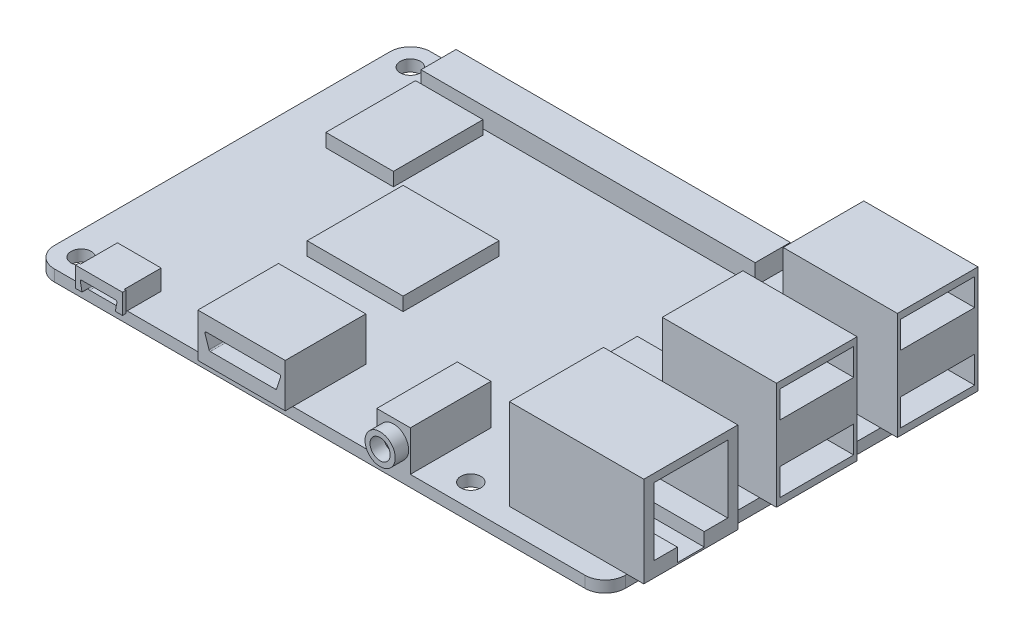
from build123d import *

# Parameters (mm, degrees)
SKETCH1_R            = 3
SKETCH1_R_2          = 1.5
BOSS_EXTRUDE1_DEPTH  = 1.7
SKETCH4_W            = 49.75
SKETCH4_H            = 5.233449475
BOSS_EXTRUDE4_DEPTH  = 3
SKETCH7_W            = 6.5
SKETCH7_H            = 5.5
SKETCH7_W_2          = 7
SKETCH7_H_2          = 0.5
BOSS_EXTRUDE7_DEPTH  = 3
SKETCH8_W            = 13
SKETCH8_H            = 12
BOSS_EXTRUDE8_DEPTH  = 6.5
SKETCH9_W            = 5
SKETCH9_H            = 12
BOSS_EXTRUDE9_DEPTH  = 6
SKETCH10_W           = 20
SKETCH10_H           = 14
BOSS_EXTRUDE10_DEPTH = 13.5
SKETCH11_W           = 17
SKETCH11_H           = 12
BOSS_EXTRUDE11_DEPTH = 16
SKETCH12_W           = 10.053569384
SKETCH12_H           = 13.342225903
SKETCH12_W_2         = 14.279787724
SKETCH12_H_2         = 14.279787724
SKETCH12_W_3         = 9
SKETCH12_H_3         = 9
BOSS_EXTRUDE12_DEPTH = 2
SKETCH13_R           = 2.25
SKETCH13_R_2         = 1.5
BOSS_EXTRUDE13_DEPTH = 2
CUT_EXTRUDE1_DEPTH   = 9
CUT_EXTRUDE2_DEPTH   = 5
SKETCH16_W           = 11
SKETCH16_H           = 4
CUT_EXTRUDE3_DEPTH   = 10
SKETCH17_W           = 11
SKETCH17_H           = 4
CUT_EXTRUDE4_DEPTH   = 10
CUT_EXTRUDE5_DEPTH   = 12


with BuildPart() as part:
    # Sketch1 → Boss-Extrude1 (new body)
    with BuildSketch(Plane(origin=(0, 0, 0), x_dir=(1, 0, 0), z_dir=(0, 1, 0))):
        with BuildLine():
            ThreePointArc((39.5, 24.5), (41.621320344, 23.621320344), (42.5, 21.5))
            Line((42.5, 21.5), (42.5, -28.5))
            ThreePointArc((42.5, -28.5), (41.621320344, -30.621320344), (39.5, -31.5))
            Line((39.5, -31.5), (-39.5, -31.5))
            ThreePointArc((-39.5, -31.5), (-41.621320344, -30.621320344), (-42.5, -28.5))
            Line((-42.5, -28.5), (-42.5, 21.5))
            ThreePointArc((-42.5, 21.5), (-41.621320344, 23.621320344), (-39.5, 24.5))
            Line((-39.5, 24.5), (39.5, 24.5))
        make_face()
        with Locations((19, -28)):
            Circle(SKETCH1_R, mode=Mode.SUBTRACT)
        with Locations((19, 21)):
            Circle(SKETCH1_R, mode=Mode.SUBTRACT)
        with Locations((-39, -28)):
            Circle(SKETCH1_R, mode=Mode.SUBTRACT)
        with Locations((-39, 21)):
            Circle(SKETCH1_R, mode=Mode.SUBTRACT)
        with Locations((19, 21)):
            Circle(SKETCH1_R)
        with Locations((19, 21)):
            Circle(SKETCH1_R_2, mode=Mode.SUBTRACT)
        with Locations((-39, 21)):
            Circle(SKETCH1_R)
        with Locations((-39, 21)):
            Circle(SKETCH1_R_2, mode=Mode.SUBTRACT)
        with Locations((-39, -28)):
            Circle(SKETCH1_R)
        with Locations((-39, -28)):
            Circle(SKETCH1_R_2, mode=Mode.SUBTRACT)
        with Locations((19, -28)):
            Circle(SKETCH1_R)
        with Locations((19, -28)):
            Circle(SKETCH1_R_2, mode=Mode.SUBTRACT)
    extrude(amount=BOSS_EXTRUDE1_DEPTH)

    # Sketch4 → Boss-Extrude4 (add)
    with BuildSketch(Plane(origin=(0, 1.7, 0), x_dir=(1, 0, 0), z_dir=(0, 1, 0))):
        with Locations((-10, 21.068102783)):
            Rectangle(SKETCH4_W, SKETCH4_H)
    extrude(amount=BOSS_EXTRUDE4_DEPTH)

    # Sketch7 → Boss-Extrude7 (add)
    with BuildSketch(Plane(origin=(0, 1.7, 0), x_dir=(1, 0, 0), z_dir=(0, 1, 0))):
        with Locations((-31.9, -29.194183223)):
            Rectangle(SKETCH7_W, SKETCH7_H)
        with Locations((-31.9, -32.194183223)):
            Rectangle(SKETCH7_W_2, SKETCH7_H_2)
    extrude(amount=BOSS_EXTRUDE7_DEPTH)

    # Sketch8 → Boss-Extrude8 (add)
    with BuildSketch(Plane(origin=(0, 1.7, 0), x_dir=(1, 0, 0), z_dir=(0, 1, 0))):
        with Locations((-10.5, -26.626453528)):
            Rectangle(SKETCH8_W, SKETCH8_H)
    extrude(amount=BOSS_EXTRUDE8_DEPTH)

    # Sketch9 → Boss-Extrude9 (add)
    with BuildSketch(Plane(origin=(0, 1.7, 0), x_dir=(1, 0, 0), z_dir=(0, 1, 0))):
        with Locations((11, -25.5)):
            Rectangle(SKETCH9_W, SKETCH9_H)
    extrude(amount=BOSS_EXTRUDE9_DEPTH)

    # Sketch10 → Boss-Extrude10 (add)
    with BuildSketch(Plane(origin=(0, 1.7, 0), x_dir=(1, 0, 0), z_dir=(0, 1, 0))):
        with Locations((35, -21.25)):
            Rectangle(SKETCH10_W, SKETCH10_H)
    extrude(amount=BOSS_EXTRUDE10_DEPTH)

    # Sketch11 → Boss-Extrude11 (add)
    with BuildSketch(Plane(origin=(0, 1.7, 0), x_dir=(1, 0, 0), z_dir=(0, 1, 0))):
        with Locations((36.5, -2.5)):
            Rectangle(SKETCH11_W, SKETCH11_H)
        with Locations((36.5, 15.5)):
            Rectangle(SKETCH11_W, SKETCH11_H)
    extrude(amount=BOSS_EXTRUDE11_DEPTH)

    # Sketch12 → Boss-Extrude12 (add)
    with BuildSketch(Plane(origin=(0, 1.7, 0), x_dir=(1, 0, 0), z_dir=(0, 1, 0))):
        with Locations((-29.848215308, 10.97382243)):
            Rectangle(SKETCH12_W, SKETCH12_H)
        with Locations((-15.157331854, -3.918986484)):
            Rectangle(SKETCH12_W_2, SKETCH12_H_2)
        with Locations((19.1, -3.31)):
            Rectangle(SKETCH12_W_3, SKETCH12_H_3)
    extrude(amount=BOSS_EXTRUDE12_DEPTH)

    # Sketch13 → Boss-Extrude13 (add)
    with BuildSketch(Plane.XY.offset(31.5)):
        with Locations((11, 4.7)):
            Circle(SKETCH13_R)
        with Locations((11, 4.7)):
            Circle(SKETCH13_R_2, mode=Mode.SUBTRACT)
    extrude(amount=BOSS_EXTRUDE13_DEPTH)

    # Sketch14 → Cut-Extrude1 (cut)
    with BuildSketch(Plane.XY.offset(32.626453528)):
        with BuildLine():
            Line((-15.750323675, 5.983842352), (-4.86762122, 5.983842352))
            ThreePointArc((-4.86762122, 5.983842352), (-4.705559797, 5.901043441), (-4.677683467, 5.721203306))
            Line((-4.677683467, 5.721203306), (-5.276717124, 3.904778668))
            ThreePointArc((-5.276717124, 3.904778668), (-5.349453787, 3.805356292), (-5.466654877, 3.767417714))
            Line((-5.466654877, 3.767417714), (-15.151290018, 3.767417714))
            ThreePointArc((-15.151290018, 3.767417714), (-15.268491107, 3.805356292), (-15.341227771, 3.904778668))
            Line((-15.341227771, 3.904778668), (-15.940261428, 5.721203306))
            ThreePointArc((-15.940261428, 5.721203306), (-15.912385097, 5.901043441), (-15.750323675, 5.983842352))
        make_face()
    extrude(amount=-CUT_EXTRUDE1_DEPTH, mode=Mode.SUBTRACT)

    # Sketch15 → Cut-Extrude2 (cut)
    with BuildSketch(Plane.XY.offset(32.444183223)):
        with BuildLine():
            Line((-34.475250903, 3.20419671), (-29.43081526, 3.20419671))
            ThreePointArc((-29.43081526, 3.20419671), (-29.27664987, 3.131605628), (-29.234394805, 2.966527034))
            Line((-29.234394805, 2.966527034), (-29.471007813, 1.732759202))
            ThreePointArc((-29.471007813, 1.732759202), (-29.540019351, 1.616263488), (-29.667428269, 1.570428878))
            Line((-29.667428269, 1.570428878), (-34.24114908, 1.570428878))
            ThreePointArc((-34.24114908, 1.570428878), (-34.36870932, 1.616388672), (-34.437643137, 1.733145027))
            Line((-34.437643137, 1.733145027), (-34.67174496, 2.966912859))
            ThreePointArc((-34.67174496, 2.966912859), (-34.62929111, 3.13175695), (-34.475250903, 3.20419671))
        make_face()
    extrude(amount=-CUT_EXTRUDE2_DEPTH, mode=Mode.SUBTRACT)

    # Sketch16 → Cut-Extrude3 (cut)
    with BuildSketch(Plane(origin=(45, 0, 0), x_dir=(0, 0, -1), z_dir=(1, 0, 0))):
        with Locations((-2.5, 4.7)):
            Rectangle(SKETCH16_W, SKETCH16_H)
        with Locations((-2.5, 14.7)):
            Rectangle(SKETCH16_W, SKETCH16_H)
    extrude(amount=-CUT_EXTRUDE3_DEPTH, mode=Mode.SUBTRACT)

    # Sketch17 → Cut-Extrude4 (cut)
    with BuildSketch(Plane(origin=(45, 0, 0), x_dir=(0, 0, -1), z_dir=(1, 0, 0))):
        with Locations((15.5, 14.7)):
            Rectangle(SKETCH17_W, SKETCH17_H)
        with Locations((15.5, 4.7)):
            Rectangle(SKETCH17_W, SKETCH17_H)
    extrude(amount=-CUT_EXTRUDE4_DEPTH, mode=Mode.SUBTRACT)

    # Sketch18 → Cut-Extrude5 (cut)
    with BuildSketch(Plane(origin=(45, 0, 0), x_dir=(0, 0, -1), z_dir=(1, 0, 0))):
        Polygon((-26.75, 14), (-26.75, 3.95), (-23.25, 3.95), (-23.25, 1.95), (-19.25, 1.95), (-19.25, 3.95), (-15.75, 3.95), (-15.75, 14), align=None)
    extrude(amount=-CUT_EXTRUDE5_DEPTH, mode=Mode.SUBTRACT)


solid = part.part
